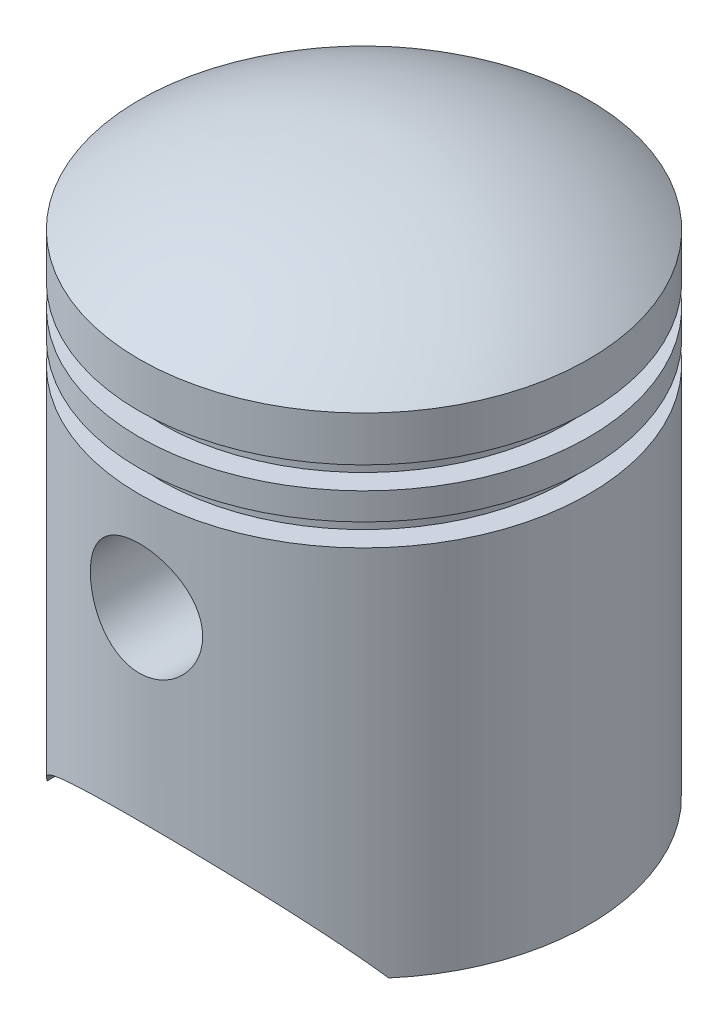
from build123d import *

# Parameters (mm, degrees)
CUT_EXTRUDE1_DEPTH      = 26.0000001
CUT_EXTRUDE1_DEPTH_BACK = 26.0000001
SKETCH3_R               = 6.25
CUT_EXTRUDE2_DEPTH      = 26.0000001
CUT_EXTRUDE2_DEPTH_BACK = 26.0000001
SKETCH5_R               = 7.25
SKETCH5_R_2             = 6.25
BOSS_EXTRUDE1_DEPTH     = 11


with BuildPart() as part:
    # Sketch1 → Revolve1 (revolve)
    with BuildSketch(Plane.XY):
        with BuildLine():
            Line((0, 62.5), (0, 60.49936285))
            ThreePointArc((0, 60.49936285), (12.069492637, 58.859165445), (23, 53.484511145))
            Line((23, 53.484511145), (23, 51.5))
            Line((23, 51.5), (20.5, 51.5))
            Line((20.5, 51.5), (20.5, 45.5))
            Line((20.5, 45.5), (20.5, 39.5))
            Line((20.5, 39.5), (23, 39.5))
            Line((23, 39.5), (23, 0))
            Line((23, 0), (25, 0))
            Line((25, 0), (25, 41.5))
            Line((25, 41.5), (22.5, 41.5))
            Line((22.5, 41.5), (22.5, 44))
            Line((22.5, 44), (25, 44))
            Line((25, 44), (25, 47))
            Line((25, 47), (22.5, 47))
            Line((22.5, 47), (22.5, 49.5))
            Line((22.5, 49.5), (25, 49.5))
            Line((25, 49.5), (25, 54.5))
            ThreePointArc((25, 54.5), (13.174901691, 60.609067785), (0, 62.5))
        make_face()
    revolve(axis=Axis((0, 62.5, 0), (0, -1, 0)))

    # Sketch2 → Cut-Extrude1 (cut, two sides)
    with BuildSketch(Plane.XY) as cut_extrude1_sk:
        with BuildLine():
            Line((19, 0), (-19, 0))
            ThreePointArc((-19, 0), (0, 10.001982606), (19, 0))
        make_face()
    extrude(amount=CUT_EXTRUDE1_DEPTH, mode=Mode.SUBTRACT)
    extrude(cut_extrude1_sk.sketch, amount=-CUT_EXTRUDE1_DEPTH_BACK, mode=Mode.SUBTRACT)

    # Sketch3 → Cut-Extrude2 (cut, two sides)
    with BuildSketch(Plane.XY) as cut_extrude2_sk:
        with Locations((0, 30.5)):
            Circle(SKETCH3_R)
    extrude(amount=CUT_EXTRUDE2_DEPTH, mode=Mode.SUBTRACT)
    extrude(cut_extrude2_sk.sketch, amount=-CUT_EXTRUDE2_DEPTH_BACK, mode=Mode.SUBTRACT)

    # Sketch5 → Boss-Extrude1 (add)
    with BuildSketch(Plane.XY.offset(12)):
        with Locations((0, 30.5)):
            Circle(SKETCH5_R)
        with Locations((0, 30.5)):
            Circle(SKETCH5_R_2, mode=Mode.SUBTRACT)
    boss_extrude1 = extrude(amount=BOSS_EXTRUDE1_DEPTH)

    # Mirror1: Boss-Extrude1 across plane
    add(boss_extrude1.mirror(Plane.XY))


solid = part.part
